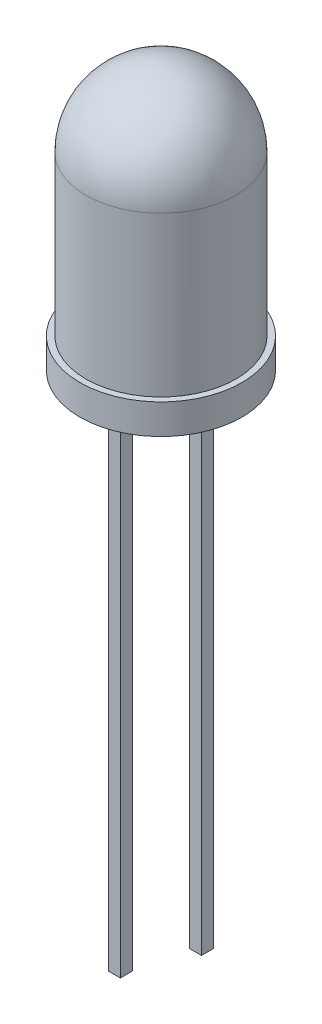
from build123d import *

# Parameters (mm, degrees)
BOSS_EXTRUDE1_DEPTH      = 0.2
BOSS_EXTRUDE1_DEPTH_BACK = 0.2
SKETCH2_W                = 0.4
SKETCH2_H                = 16
SKETCH2_H_2              = 18


with BuildPart() as part:
    # Sketch1 → Revolve1 (revolve)
    with BuildSketch(Plane.XY):
        with BuildLine():
            Line((0, 0), (2.7, 0))
            Line((2.7, 0), (2.7, 1))
            Line((2.7, 1), (2.5, 1))
            Line((2.5, 1), (2.5, 6.3))
            ThreePointArc((2.5, 6.3), (1.767766953, 8.067766953), (0, 8.8))
            Line((0, 8.8), (0, 0))
        make_face()
    revolve(axis=Axis((0, 8.8, 0), (0, -1, 0)))

    # Sketch2 → Boss-Extrude1 (add, two sides: drawn at the far end of the back side and taken through both)
    with BuildSketch(Plane.XY.offset(-BOSS_EXTRUDE1_DEPTH_BACK)):
        with Locations((1.35, -8)):
            Rectangle(SKETCH2_W, SKETCH2_H)
        with Locations((-1.35, -9)):
            Rectangle(SKETCH2_W, SKETCH2_H_2)
    extrude(amount=BOSS_EXTRUDE1_DEPTH + BOSS_EXTRUDE1_DEPTH_BACK)


solid = part.part
